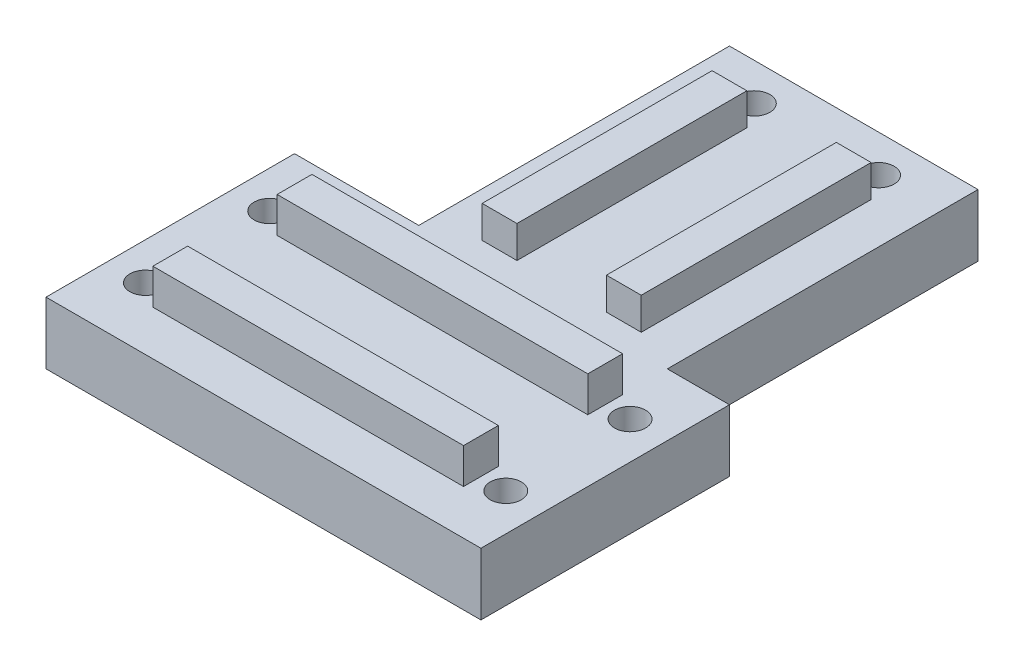
from build123d import *

# Parameters (mm, degrees)
SALIENTE_EXTRUIR1_DEPTH = 10
SALIENTE_EXTRUIR3_DEPTH = 100
CROQUIS5_W              = 40
CROQUIS5_H              = 50
SALIENTE_EXTRUIR5_DEPTH = 10
SALIENTE_EXTRUIR7_DEPTH = 47
CROQUIS11_W             = 74.096638428
CROQUIS11_H             = 162.244793696
CORTAR_EXTRUIR3_DEPTH   = 30
CROQUIS9_W              = 10
CROQUIS9_H              = 40
CROQUIS9_W_2            = 40
CROQUIS9_H_2            = 10
CORTAR_EXTRUIR1_DEPTH   = 6.711119453
CROQUIS12_R             = 2.5
CORTAR_EXTRUIR4_DEPTH   = 11


with BuildPart() as part:
    # Croquis1 → Saliente-Extruir1 (new body)
    with BuildSketch(Plane(origin=(0, 0, 0), x_dir=(1, 0, 0), z_dir=(0, 1, 0))):
        Polygon((30, 20), (-30, 20), (-70, 20), (-70, -20), (-30, -20), (30, -20), align=None)
    extrude(amount=SALIENTE_EXTRUIR1_DEPTH)

    # Croquis3 → Saliente-Extruir3 (add, through all)
    with BuildSketch(Plane.ZY.offset(70)):
        Polygon((10, 10), (7.2, 10), (7.2, 15.711119453), (12.8, 15.711119453), (12.8, 10), align=None)
        Polygon((-10, 10), (-12.8, 10), (-12.8, 15.711119453), (-7.2, 15.711119453), (-7.2, 10), align=None)
    extrude(amount=-SALIENTE_EXTRUIR3_DEPTH)

    # Croquis5 → Saliente-Extruir5 (add)
    with BuildSketch(Plane(origin=(0, 10, 0), x_dir=(1, 0, 0), z_dir=(0, 1, 0))):
        with Locations((0, 45)):
            Rectangle(CROQUIS5_W, CROQUIS5_H)
    extrude(amount=-SALIENTE_EXTRUIR5_DEPTH)

    # Croquis7 → Saliente-Extruir7 (add)
    with BuildSketch(Plane(origin=(0, 0, -70), x_dir=(-1, 0, 0), z_dir=(0, 0, -1))):
        Polygon((12.8, 10), (10, 10), (7.2, 10), (7.2, 15.165648874), (12.8, 15.165648874), align=None)
        Polygon((-7.2, 10), (-10, 10), (-12.8, 10), (-12.8, 15.165648874), (-7.2, 15.165648874), align=None)
    extrude(amount=-SALIENTE_EXTRUIR7_DEPTH)

    # Croquis11 → Cortar-Extruir3 (cut)
    with BuildSketch(Plane.ZY.offset(70)):
        Rectangle(CROQUIS11_W, CROQUIS11_H)
    extrude(amount=-CORTAR_EXTRUIR3_DEPTH, mode=Mode.SUBTRACT)

    # Croquis9 → Cortar-Extruir1 (cut, through all)
    with BuildSketch(Plane(origin=(0, 10, 0), x_dir=(1, 0, 0), z_dir=(0, 1, 0))):
        with Locations((25, 0)):
            Rectangle(CROQUIS9_W, CROQUIS9_H)
        with Locations((0, 65)):
            Rectangle(CROQUIS9_W_2, CROQUIS9_H_2)
        with Locations((-35, 0)):
            Rectangle(CROQUIS9_W, CROQUIS9_H)
    extrude(amount=CORTAR_EXTRUIR1_DEPTH, mode=Mode.SUBTRACT)

    # Croquis12 → Cortar-Extruir4 (cut, through all)
    with BuildSketch(Plane(origin=(0, 10, 0), x_dir=(1, 0, 0), z_dir=(0, 1, 0))):
        with Locations((24, -10)):
            Circle(CROQUIS12_R)
        with Locations((24, 10)):
            Circle(CROQUIS12_R)
        with Locations((-34, -10)):
            Circle(CROQUIS12_R)
        with Locations((-34, 10)):
            Circle(CROQUIS12_R)
        with Locations((10, 64)):
            Circle(CROQUIS12_R)
        with Locations((-10, 64)):
            Circle(CROQUIS12_R)
    extrude(amount=-CORTAR_EXTRUIR4_DEPTH, mode=Mode.SUBTRACT)


solid = part.part
